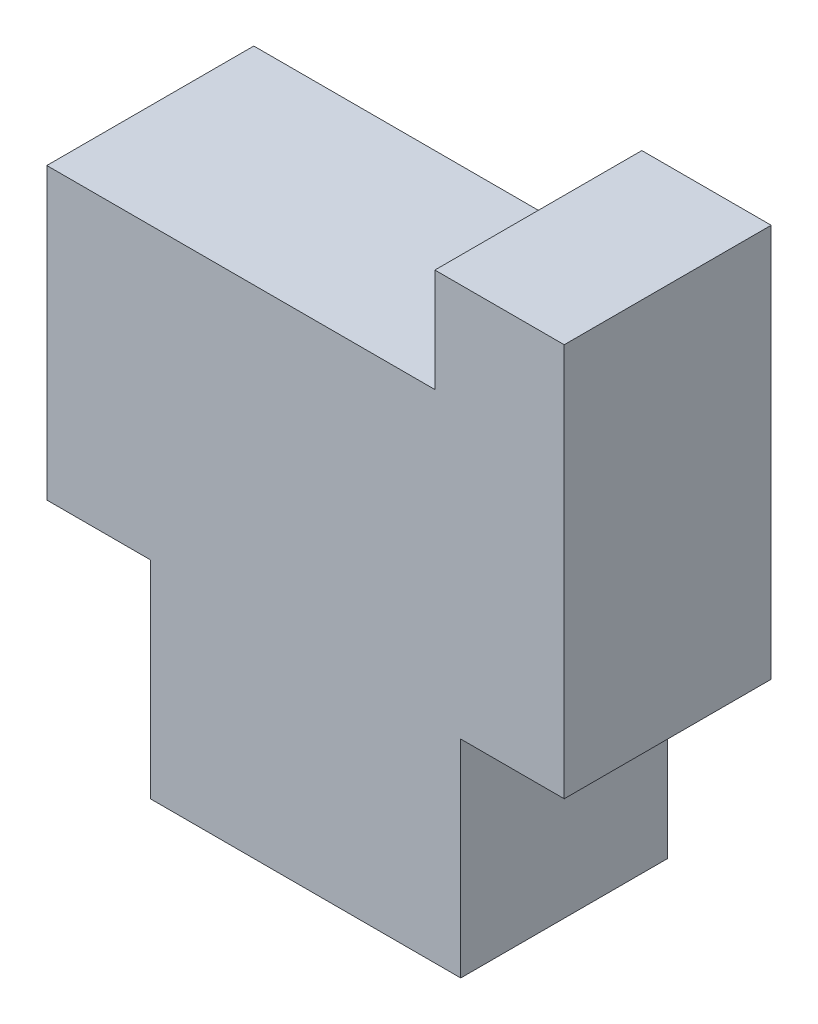
from build123d import *

# Parameters (mm, degrees)
BOSS_EXTRUDE1_DEPTH = 4


with BuildPart() as part:
    # Sketch1 → Boss-Extrude1 (new body)
    with BuildSketch(Plane.XY):
        Polygon((0, 0), (6, 0), (6, 4), (8, 4), (8, 11.6), (5.5, 11.6), (5.5, 9.6), (-2, 9.6), (-2, 4), (0, 4), align=None)
    extrude(amount=BOSS_EXTRUDE1_DEPTH)


solid = part.part
